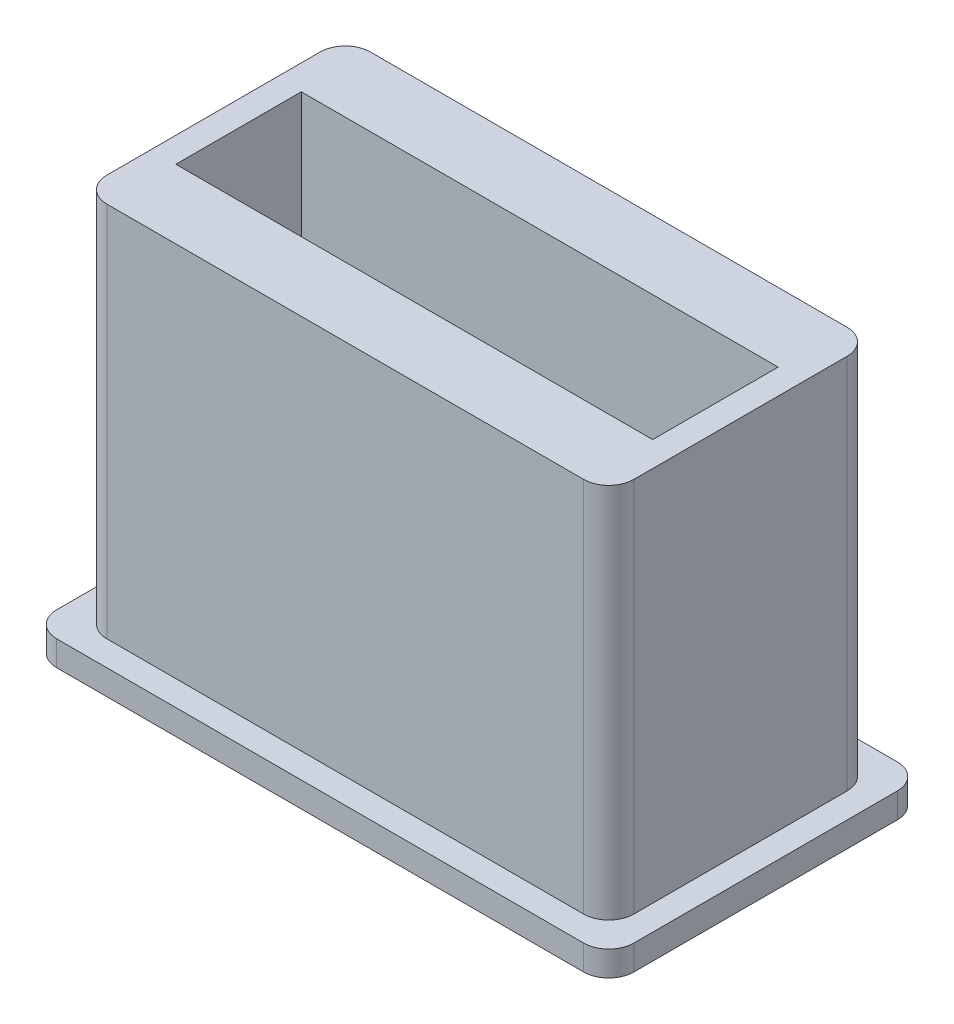
from build123d import *

# Parameters (mm, degrees)
SKETCH2_W           = 210
SKETCH2_H           = 105
SKETCH2_W_2         = 190
SKETCH2_H_2         = 50
BOSS_EXTRUDE2_DEPTH = 150
FILLET1_R           = 10
FILLET2_R           = 10
FILLET3_R           = 10
FILLET4_R           = 10
SKETCH3_R           = 16.1
CUT_EXTRUDE1_DEPTH  = 10
SKETCH4_W           = 230
SKETCH4_H           = 125
BOSS_EXTRUDE3_DEPTH = 10
FILLET5_R           = 10
FILLET6_R           = 10
FILLET7_R           = 10
FILLET8_R           = 10
SKETCH7_W           = 10
SKETCH7_H           = 50
BOSS_EXTRUDE4_DEPTH = 75
SKETCH8_R           = 16.1
CUT_EXTRUDE2_DEPTH  = 10


with BuildPart() as part:
    # Sketch2 → Boss-Extrude2 (new body)
    with BuildSketch(Plane(origin=(0, 0, 0), x_dir=(1, 0, 0), z_dir=(0, 1, 0))):
        Rectangle(SKETCH2_W, SKETCH2_H)
        Rectangle(SKETCH2_W_2, SKETCH2_H_2, mode=Mode.SUBTRACT)
    extrude(amount=BOSS_EXTRUDE2_DEPTH)

    # Fillet1
    fillet1_edges = [part.edges().sort_by_distance(p)[0] for p in [
        (-105, 75, -52.5),
    ]]
    fillet(fillet1_edges, radius=FILLET1_R)

    # Fillet2
    fillet2_edges = [part.edges().sort_by_distance(p)[0] for p in [
        (-105, 75, 52.5),
    ]]
    fillet(fillet2_edges, radius=FILLET2_R)

    # Fillet3
    fillet3_edges = [part.edges().sort_by_distance(p)[0] for p in [
        (105, 75, 52.5),
    ]]
    fillet(fillet3_edges, radius=FILLET3_R)

    # Fillet4
    fillet4_edges = [part.edges().sort_by_distance(p)[0] for p in [
        (105, 75, -52.5),
    ]]
    fillet(fillet4_edges, radius=FILLET4_R)

    # Sketch3 → Cut-Extrude1 (cut)
    with BuildSketch(Plane.ZY.offset(105)):
        with Locations((0, 75)):
            Circle(SKETCH3_R)
    extrude(amount=-CUT_EXTRUDE1_DEPTH, mode=Mode.SUBTRACT)

    # Sketch4 → Boss-Extrude3 (add)
    with BuildSketch(Plane(origin=(0, 0, 0), x_dir=(1, 0, 0), z_dir=(0, 1, 0))):
        Rectangle(SKETCH4_W, SKETCH4_H)
    extrude(amount=-BOSS_EXTRUDE3_DEPTH)

    # Fillet5
    fillet5_edges = [part.edges().sort_by_distance(p)[0] for p in [
        (115, -5, 62.5),
    ]]
    fillet(fillet5_edges, radius=FILLET5_R)

    # Fillet6
    fillet6_edges = [part.edges().sort_by_distance(p)[0] for p in [
        (115, -5, -62.5),
    ]]
    fillet(fillet6_edges, radius=FILLET6_R)

    # Fillet7
    fillet7_edges = [part.edges().sort_by_distance(p)[0] for p in [
        (-115, -5, -62.5),
    ]]
    fillet(fillet7_edges, radius=FILLET7_R)

    # Fillet8
    fillet8_edges = [part.edges().sort_by_distance(p)[0] for p in [
        (-115, -5, 62.5),
    ]]
    fillet(fillet8_edges, radius=FILLET8_R)

    # Sketch7 → Boss-Extrude4 (add)
    with BuildSketch(Plane(origin=(0, 0, 0), x_dir=(1, 0, 0), z_dir=(0, 1, 0))):
        Rectangle(SKETCH7_W, SKETCH7_H)
    extrude(amount=BOSS_EXTRUDE4_DEPTH)

    # Sketch8 → Cut-Extrude2 (cut)
    with BuildSketch(Plane.ZY.offset(5)):
        with Locations((0, 75)):
            Circle(SKETCH8_R)
    extrude(amount=-CUT_EXTRUDE2_DEPTH, mode=Mode.SUBTRACT)


solid = part.part
